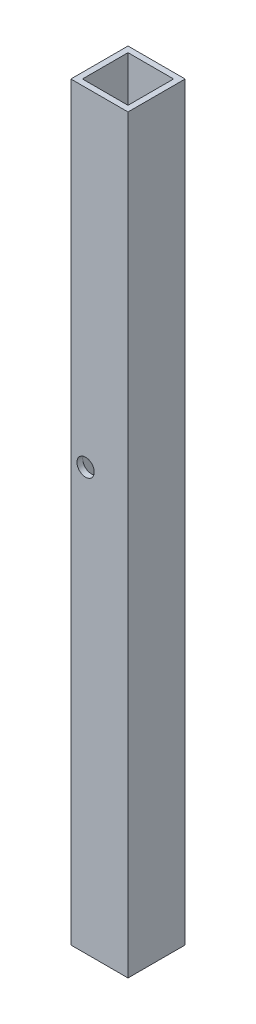
from build123d import *

# Parameters (mm, degrees)
SKETCH_1_W         = 9.9
SKETCH_1_H         = 9.9
SKETCH_1_W_2       = 7.9
SKETCH_1_H_2       = 7.9
EXTRUDE_1_DEPTH    = 130
SKETCH2_R          = 1.5
CUT_EXTRUDE2_DEPTH = 10.9


with BuildPart() as part:
    # Эскиз1 → Бобышка-Вытянуть1 (new body)
    with BuildSketch(Plane(origin=(0, 0, 0), x_dir=(1, 0, 0), z_dir=(0, 1, 0))):
        Rectangle(SKETCH_1_W, SKETCH_1_H)
        Rectangle(SKETCH_1_W_2, SKETCH_1_H_2, mode=Mode.SUBTRACT)
    extrude(amount=EXTRUDE_1_DEPTH)

    # Sketch2 → Cut-Extrude2 (cut, through all)
    with BuildSketch(Plane(origin=(0, 0, -4.95), x_dir=(-1, 0, 0), z_dir=(0, 0, -1))):
        with Locations((2.4, 73)):
            Circle(SKETCH2_R)
    extrude(amount=-CUT_EXTRUDE2_DEPTH, mode=Mode.SUBTRACT)


solid = part.part
